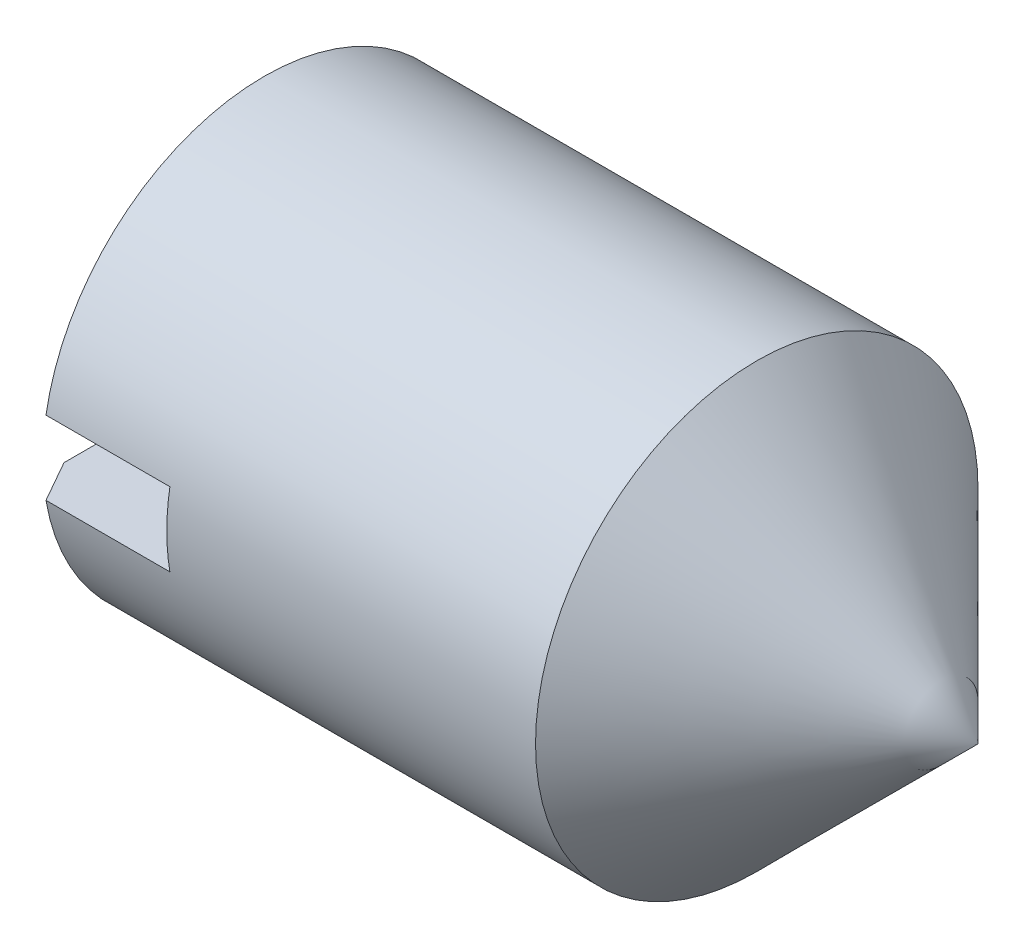
from build123d import *

# Parameters (mm, degrees)
SKETCH2_W  = 6
SKETCH2_H  = 1
SLOT_DEPTH = 2


with BuildPart() as part:
    # BodySke → BaseBody (revolve)
    with BuildSketch(Plane.XY):
        Polygon((0, 0), (0, 2.4455), (0.320140724, 3), (7, 3), (10, 0), align=None)
    revolve(axis=Axis((-12.7, 0, 0), (1, 0, 0)))

    # Sketch2 → Slot (cut)
    with BuildSketch(Plane.ZY):
        Rectangle(SKETCH2_W, SKETCH2_H)
    extrude(amount=-SLOT_DEPTH, mode=Mode.SUBTRACT)


solid = part.part
